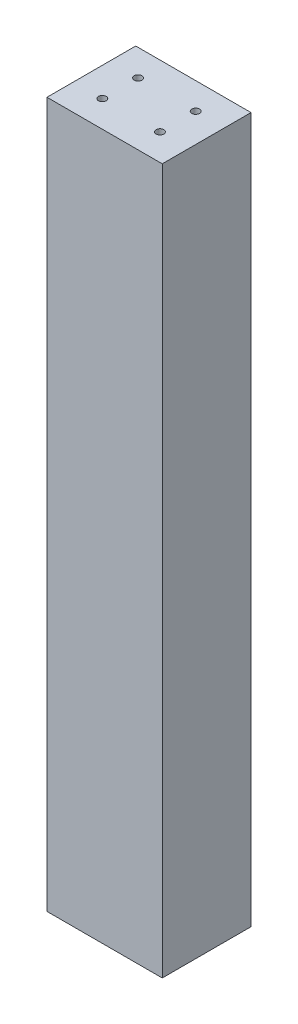
from build123d import *

# Parameters (mm, degrees)
SKETCH1_W               = 76.2
SKETCH1_H               = 58.674
BOSS_EXTRUDE1_DEPTH     = 466.09
F_1_4_20_TAPPED_HOLE1_D = 5.1054


with BuildPart() as part:
    # Sketch1 → Boss-Extrude1 (new body)
    with BuildSketch(Plane(origin=(0, 0, 0), x_dir=(1, 0, 0), z_dir=(0, 1, 0))):
        with Locations((38.1, 29.337)):
            Rectangle(SKETCH1_W, SKETCH1_H)
    extrude(amount=-BOSS_EXTRUDE1_DEPTH)

    # 1/4-20 Tapped Hole1 (through all)
    with Locations(Plane(origin=(57.15, 0, -41.148), x_dir=(0, 0, 1), z_dir=(0, 1, 0))):
        with Locations((0, 0), (23.622, 0), (0, -38.1), (23.622, -38.1), (-79.662554242, -14.323198742)):
            Hole(F_1_4_20_TAPPED_HOLE1_D / 2)


solid = part.part
